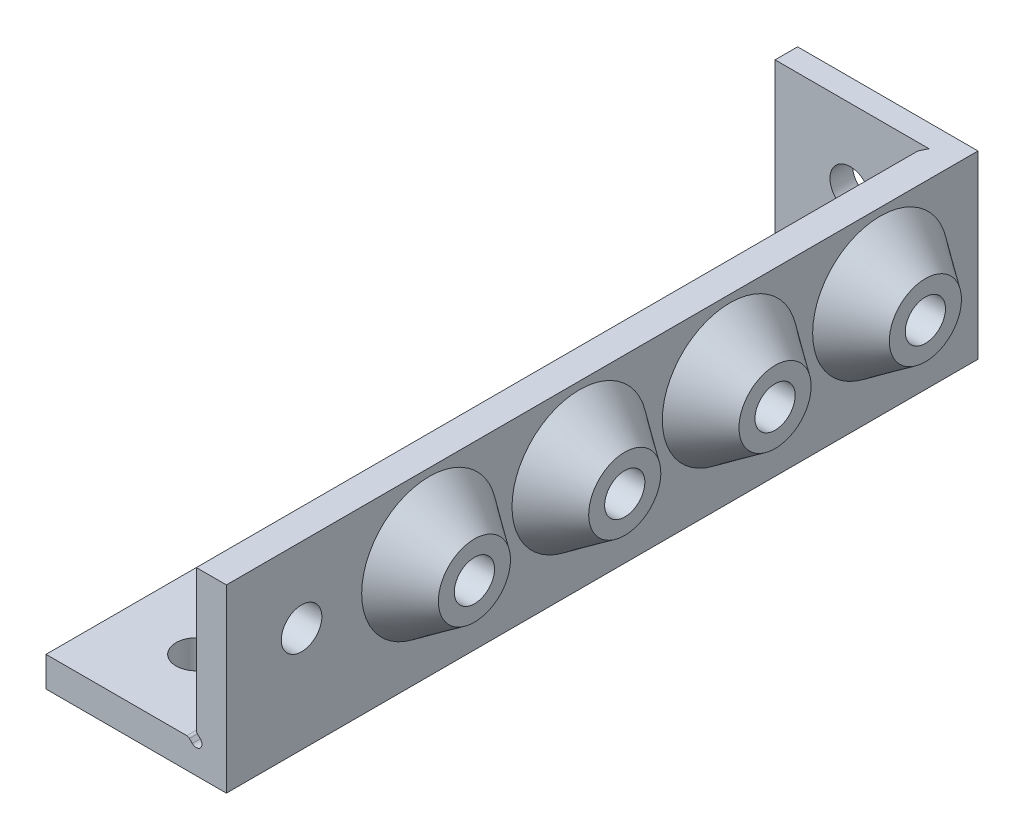
from build123d import *

# Parameters (mm, degrees)
SKETCH1_R                      = 2.7
BOSS_EXTRUDE1_DEPTH            = 3
BOSS_EXTRUDE2_DEPTH            = 100
CUT_EXTRUDE1_DEPTH             = 20
CUT_EXTRUDE2_DEPTH             = 20
SKETCH4_R                      = 9
BOSS_EXTRUDE3_DEPTH            = 6
BOSS_EXTRUDE3_TAPER            = 35
CUT_EXTRUDE3_REACH             = 26
SKETCH4_3_R                    = 2.675
SKETCH4_3_R_2                  = 2.7
CUT_EXTRUDE3_DIRECTION_2_REACH = 8
SKETCH5_R                      = 2.675
SKETCH5_R_2                    = 2.7
CUT_EXTRUDE4_DEPTH             = 10


with BuildPart() as part:
    # Sketch1 → Boss-Extrude1 (new body)
    with BuildSketch(Plane.XY):
        with BuildLine():
            Line((-1.267766953, 0), (-20, 0))
            Line((-20, 0), (-20, 20))
            Line((-20, 20), (0, 20))
            Line((0, 20), (0, 1.267766953))
            ThreePointArc((0, 1.267766953), (0.038060234, 1.076425237), (0.146446609, 0.914213562))
            Line((0.146446609, 0.914213562), (0.530330086, 0.530330086))
            ThreePointArc((0.530330086, 0.530330086), (0.530330086, -0.530330086), (-0.530330086, -0.530330086))
            Line((-0.530330086, -0.530330086), (-0.914213562, -0.146446609))
            ThreePointArc((-0.914213562, -0.146446609), (-1.076425237, -0.038060234), (-1.267766953, 0))
        make_face()
        with Locations((-10, 10)):
            Circle(SKETCH1_R, mode=Mode.SUBTRACT)
    extrude(amount=BOSS_EXTRUDE1_DEPTH)

    # Sketch1_4 → Boss-Extrude2 (add)
    with BuildSketch(Plane.XY):
        with BuildLine():
            ThreePointArc((-1.267766953, 0), (-1.076425237, -0.038060234), (-0.914213562, -0.146446609))
            Line((-0.914213562, -0.146446609), (-0.530330086, -0.530330086))
            ThreePointArc((-0.530330086, -0.530330086), (0.530330086, -0.530330086), (0.530330086, 0.530330086))
            Line((0.530330086, 0.530330086), (0.146446609, 0.914213562))
            ThreePointArc((0.146446609, 0.914213562), (0.038060234, 1.076425237), (0, 1.267766953))
            Line((0, 1.267766953), (0, 20))
            Line((0, 20), (4, 20))
            Line((4, 20), (4, -4))
            Line((4, -4), (-20, -4))
            Line((-20, -4), (-20, 0))
            Line((-20, 0), (-1.267766953, 0))
        make_face()
    extrude(amount=BOSS_EXTRUDE2_DEPTH)

    # Sketch2 → Cut-Extrude1 (cut)
    with BuildSketch(Plane(origin=(0, 20, 0), x_dir=(1, 0, 0), z_dir=(0, 1, 0))):
        Polygon((0, -3), (0.5, -3), (0, -4), align=None)
    extrude(amount=-CUT_EXTRUDE1_DEPTH, mode=Mode.SUBTRACT)

    # Sketch3 → Cut-Extrude2 (cut)
    with BuildSketch(Plane.ZY.offset(20)):
        Polygon((3, 0), (3, -0.5), (4, 0), align=None)
    extrude(amount=-CUT_EXTRUDE2_DEPTH, mode=Mode.SUBTRACT)

    # Sketch4 → Boss-Extrude3 (add)
    with BuildSketch(Plane(origin=(4, 0, 0), x_dir=(0, 0, -1), z_dir=(1, 0, 0))):
        with Locations((-13, 10)):
            Circle(SKETCH4_R)
        with Locations((-33, 10)):
            Circle(SKETCH4_R)
        with Locations((-53, 10)):
            Circle(SKETCH4_R)
        with Locations((-73, 10)):
            Circle(SKETCH4_R)
    boss_extrude3 = extrude(amount=BOSS_EXTRUDE3_DEPTH, taper=BOSS_EXTRUDE3_TAPER)

    # Cut-Extrude3: up to this face of the body (flat: up to its plane)
    cut_extrude3_end = Plane(part.part.faces().sort_by_distance((0, 10.633883476, 52))[0])
    # Sketch4_3 → Cut-Extrude3 (cut, up to the picked face)
    with BuildSketch(Plane(origin=(4, 0, 0), x_dir=(0, 0, -1), z_dir=(1, 0, 0)), mode=Mode.PRIVATE) as cut_extrude3_sk1:
        with Locations((-13, 10)):
            Circle(SKETCH4_3_R)
    cut_extrude3_tool1 = split(extrude(cut_extrude3_sk1.sketch, amount=-CUT_EXTRUDE3_REACH, mode=Mode.PRIVATE), bisect_by=cut_extrude3_end, keep=Keep.BOTH, mode=Mode.PRIVATE)
    add(cut_extrude3_tool1.solids().sort_by_distance((4, 10, 13))[0], mode=Mode.SUBTRACT)
    # Sketch4_3 → Cut-Extrude3 (cut, up to the picked face)
    with BuildSketch(Plane(origin=(4, 0, 0), x_dir=(0, 0, -1), z_dir=(1, 0, 0)), mode=Mode.PRIVATE) as cut_extrude3_sk2:
        with Locations((-33, 10)):
            Circle(SKETCH4_3_R)
    cut_extrude3_tool2 = split(extrude(cut_extrude3_sk2.sketch, amount=-CUT_EXTRUDE3_REACH, mode=Mode.PRIVATE), bisect_by=cut_extrude3_end, keep=Keep.BOTH, mode=Mode.PRIVATE)
    add(cut_extrude3_tool2.solids().sort_by_distance((4, 10, 33))[0], mode=Mode.SUBTRACT)
    # Sketch4_3 → Cut-Extrude3 (cut, up to the picked face)
    with BuildSketch(Plane(origin=(4, 0, 0), x_dir=(0, 0, -1), z_dir=(1, 0, 0)), mode=Mode.PRIVATE) as cut_extrude3_sk3:
        with Locations((-53, 10)):
            Circle(SKETCH4_3_R)
    cut_extrude3_tool3 = split(extrude(cut_extrude3_sk3.sketch, amount=-CUT_EXTRUDE3_REACH, mode=Mode.PRIVATE), bisect_by=cut_extrude3_end, keep=Keep.BOTH, mode=Mode.PRIVATE)
    add(cut_extrude3_tool3.solids().sort_by_distance((4, 10, 53))[0], mode=Mode.SUBTRACT)
    # Sketch4_3 → Cut-Extrude3 (cut, up to the picked face)
    with BuildSketch(Plane(origin=(4, 0, 0), x_dir=(0, 0, -1), z_dir=(1, 0, 0)), mode=Mode.PRIVATE) as cut_extrude3_sk4:
        with Locations((-73, 10)):
            Circle(SKETCH4_3_R)
    cut_extrude3_tool4 = split(extrude(cut_extrude3_sk4.sketch, amount=-CUT_EXTRUDE3_REACH, mode=Mode.PRIVATE), bisect_by=cut_extrude3_end, keep=Keep.BOTH, mode=Mode.PRIVATE)
    add(cut_extrude3_tool4.solids().sort_by_distance((4, 10, 73))[0], mode=Mode.SUBTRACT)
    # Sketch4_3 → Cut-Extrude3 (cut, up to the picked face)
    with BuildSketch(Plane(origin=(4, 0, 0), x_dir=(0, 0, -1), z_dir=(1, 0, 0)), mode=Mode.PRIVATE) as cut_extrude3_sk5:
        with Locations((-90, 10)):
            Circle(SKETCH4_3_R_2)
    cut_extrude3_tool5 = split(extrude(cut_extrude3_sk5.sketch, amount=-CUT_EXTRUDE3_REACH, mode=Mode.PRIVATE), bisect_by=cut_extrude3_end, keep=Keep.BOTH, mode=Mode.PRIVATE)
    add(cut_extrude3_tool5.solids().sort_by_distance((4, 10, 90))[0], mode=Mode.SUBTRACT)

    # Cut-Extrude3 direction 2: up to this face of the body (flat: up to its plane)
    cut_extrude3_direction_2_end = Plane(part.part.faces().sort_by_distance((10, 10, 73))[0])
    # Sketch4_3 → Cut-Extrude3 direction 2 (cut, up to the picked face)
    with BuildSketch(Plane(origin=(4, 0, 0), x_dir=(0, 0, -1), z_dir=(1, 0, 0)), mode=Mode.PRIVATE) as cut_extrude3_direction_2_sk1:
        with Locations((-13, 10)):
            Circle(SKETCH4_3_R)
    cut_extrude3_direction_2_tool1 = split(extrude(cut_extrude3_direction_2_sk1.sketch, amount=CUT_EXTRUDE3_DIRECTION_2_REACH, mode=Mode.PRIVATE), bisect_by=cut_extrude3_direction_2_end, keep=Keep.BOTH, mode=Mode.PRIVATE)
    add(cut_extrude3_direction_2_tool1.solids().sort_by_distance((4, 10, 13))[0], mode=Mode.SUBTRACT)
    # Sketch4_3 → Cut-Extrude3 direction 2 (cut, up to the picked face)
    with BuildSketch(Plane(origin=(4, 0, 0), x_dir=(0, 0, -1), z_dir=(1, 0, 0)), mode=Mode.PRIVATE) as cut_extrude3_direction_2_sk2:
        with Locations((-33, 10)):
            Circle(SKETCH4_3_R)
    cut_extrude3_direction_2_tool2 = split(extrude(cut_extrude3_direction_2_sk2.sketch, amount=CUT_EXTRUDE3_DIRECTION_2_REACH, mode=Mode.PRIVATE), bisect_by=cut_extrude3_direction_2_end, keep=Keep.BOTH, mode=Mode.PRIVATE)
    add(cut_extrude3_direction_2_tool2.solids().sort_by_distance((4, 10, 33))[0], mode=Mode.SUBTRACT)
    # Sketch4_3 → Cut-Extrude3 direction 2 (cut, up to the picked face)
    with BuildSketch(Plane(origin=(4, 0, 0), x_dir=(0, 0, -1), z_dir=(1, 0, 0)), mode=Mode.PRIVATE) as cut_extrude3_direction_2_sk3:
        with Locations((-53, 10)):
            Circle(SKETCH4_3_R)
    cut_extrude3_direction_2_tool3 = split(extrude(cut_extrude3_direction_2_sk3.sketch, amount=CUT_EXTRUDE3_DIRECTION_2_REACH, mode=Mode.PRIVATE), bisect_by=cut_extrude3_direction_2_end, keep=Keep.BOTH, mode=Mode.PRIVATE)
    add(cut_extrude3_direction_2_tool3.solids().sort_by_distance((4, 10, 53))[0], mode=Mode.SUBTRACT)
    # Sketch4_3 → Cut-Extrude3 direction 2 (cut, up to the picked face)
    with BuildSketch(Plane(origin=(4, 0, 0), x_dir=(0, 0, -1), z_dir=(1, 0, 0)), mode=Mode.PRIVATE) as cut_extrude3_direction_2_sk4:
        with Locations((-73, 10)):
            Circle(SKETCH4_3_R)
    cut_extrude3_direction_2_tool4 = split(extrude(cut_extrude3_direction_2_sk4.sketch, amount=CUT_EXTRUDE3_DIRECTION_2_REACH, mode=Mode.PRIVATE), bisect_by=cut_extrude3_direction_2_end, keep=Keep.BOTH, mode=Mode.PRIVATE)
    add(cut_extrude3_direction_2_tool4.solids().sort_by_distance((4, 10, 73))[0], mode=Mode.SUBTRACT)
    # Sketch4_3 → Cut-Extrude3 direction 2 (cut, up to the picked face)
    with BuildSketch(Plane(origin=(4, 0, 0), x_dir=(0, 0, -1), z_dir=(1, 0, 0)), mode=Mode.PRIVATE) as cut_extrude3_direction_2_sk5:
        with Locations((-90, 10)):
            Circle(SKETCH4_3_R_2)
    cut_extrude3_direction_2_tool5 = split(extrude(cut_extrude3_direction_2_sk5.sketch, amount=CUT_EXTRUDE3_DIRECTION_2_REACH, mode=Mode.PRIVATE), bisect_by=cut_extrude3_direction_2_end, keep=Keep.BOTH, mode=Mode.PRIVATE)
    add(cut_extrude3_direction_2_tool5.solids().sort_by_distance((4, 10, 90))[0], mode=Mode.SUBTRACT)

    # Mirror1: Boss-Extrude3 across plane
    add(boss_extrude3.mirror(Plane(origin=(0, 0, 0), x_dir=(0, 0, 1), z_dir=(0.707106781, 0.707106781, 0))))

    # Sketch5 → Cut-Extrude4 (cut)
    with BuildSketch(Plane.XZ.offset(10)):
        with Locations((-10, 13)):
            Circle(SKETCH5_R)
        with Locations((-10, 90)):
            Circle(SKETCH5_R_2)
        with Locations((-10, 33)):
            Circle(SKETCH5_R)
        with Locations((-10, 53)):
            Circle(SKETCH5_R)
        with Locations((-10, 73)):
            Circle(SKETCH5_R)
    extrude(amount=-CUT_EXTRUDE4_DEPTH, mode=Mode.SUBTRACT)


solid = part.part
